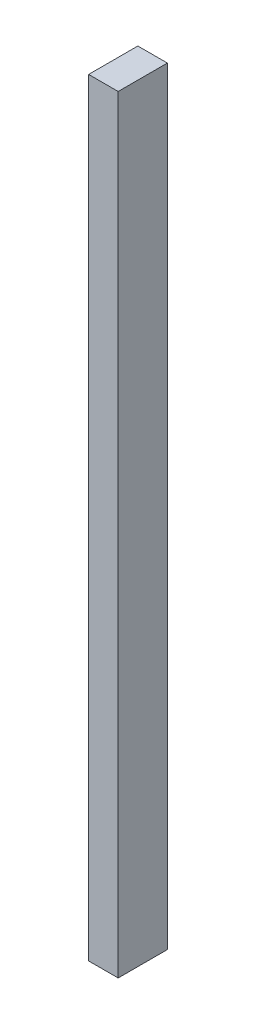
from build123d import *

# Parameters (mm, degrees)
SKETCH1_W           = 38.1
SKETCH1_H           = 63.5
BOSS_EXTRUDE1_DEPTH = 990.6


with BuildPart() as part:
    # Sketch1 → Boss-Extrude1 (new body)
    with BuildSketch(Plane(origin=(0, 0, 0), x_dir=(1, 0, 0), z_dir=(0, 1, 0))):
        Rectangle(SKETCH1_W, SKETCH1_H)
    extrude(amount=BOSS_EXTRUDE1_DEPTH)


solid = part.part
